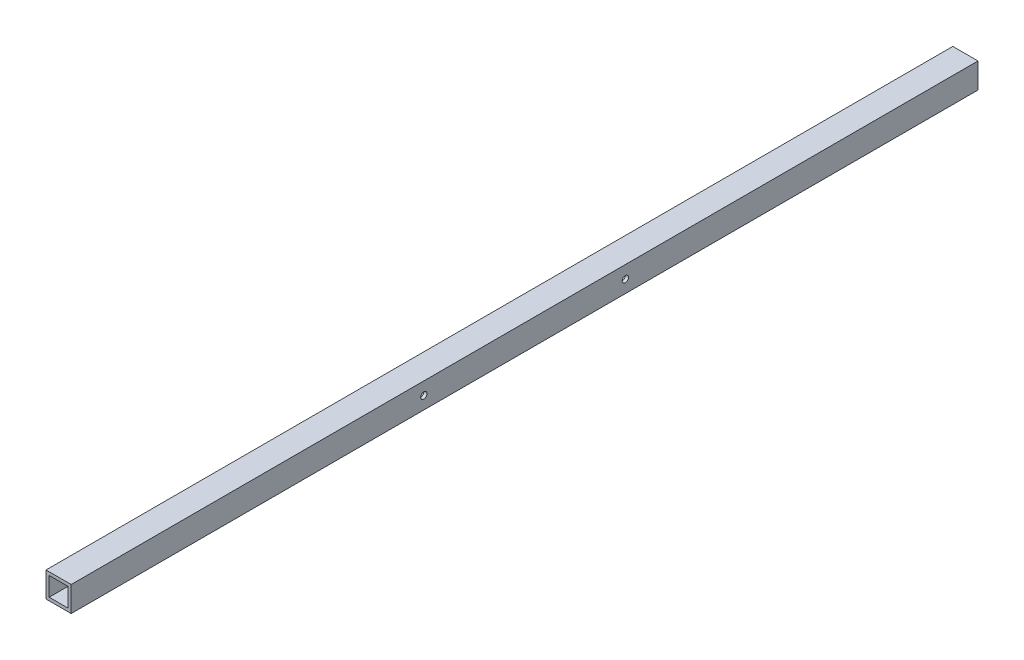
from build123d import *

# Parameters (mm, degrees)
SKETCH1_W           = 25.4
SKETCH1_H           = 25.4
SKETCH1_W_2         = 19.05
SKETCH1_H_2         = 19.05
BOSS_EXTRUDE1_DEPTH = 914.4
SKETCH2_R           = 3.175
CUT_EXTRUDE1_DEPTH  = 26.4


with BuildPart() as part:
    # Sketch1 → Boss-Extrude1 (new body)
    with BuildSketch(Plane.XY):
        Rectangle(SKETCH1_W, SKETCH1_H)
        Rectangle(SKETCH1_W_2, SKETCH1_H_2, mode=Mode.SUBTRACT)
    extrude(amount=BOSS_EXTRUDE1_DEPTH)

    # Sketch2 → Cut-Extrude1 (cut, through all)
    with BuildSketch(Plane(origin=(12.7, 0, 0), x_dir=(0, 0, -1), z_dir=(1, 0, 0))):
        with Locations((-558.8, 0)):
            Circle(SKETCH2_R)
        with Locations((-355.6, 0)):
            Circle(SKETCH2_R)
    extrude(amount=-CUT_EXTRUDE1_DEPTH, mode=Mode.SUBTRACT)


solid = part.part
